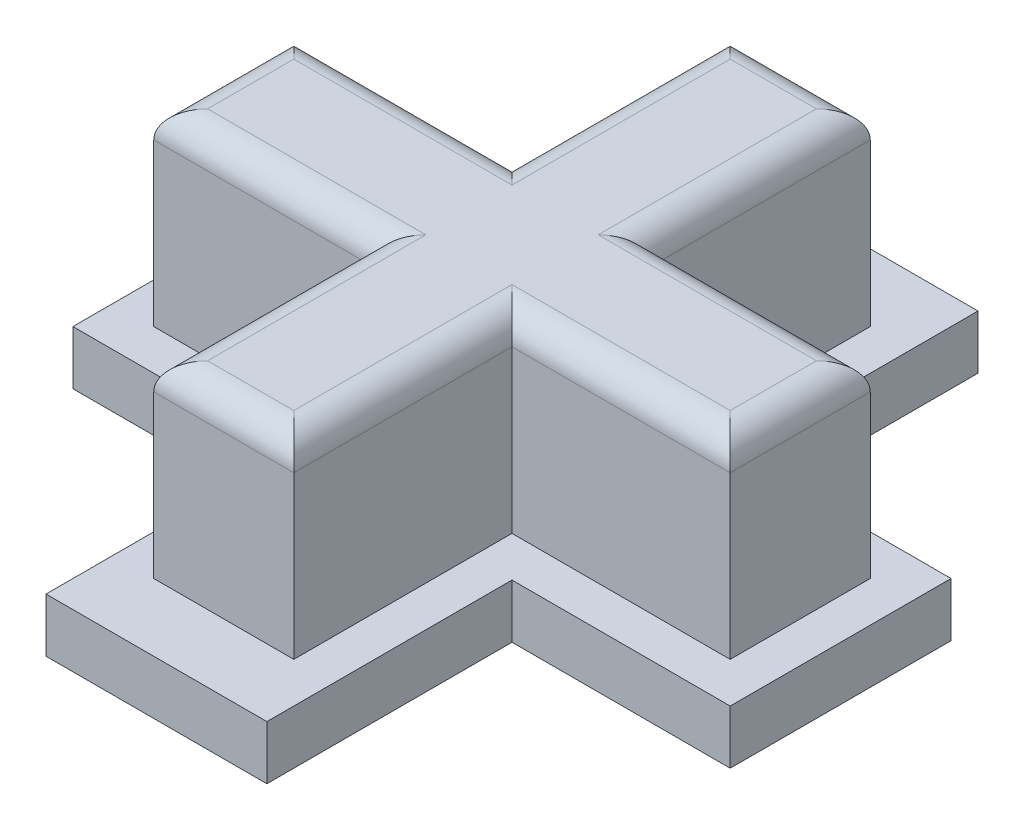
from build123d import *

# Parameters (mm, degrees)
BOSS_EXTRUDE1_DEPTH = 2
BOSS_EXTRUDE3_DEPTH = 7
FILLET5_R           = 1


with BuildPart() as part:
    # Sketch1 → Boss-Extrude1 (new body)
    with BuildSketch(Plane(origin=(0, 0, 0), x_dir=(1, 0, 0), z_dir=(0, 1, 0))):
        Polygon((4.1, -4.1), (4.1, -13.2), (-4.1, -13.2), (-4.1, -4.1), (-12.2, -4.1), (-12.2, 4.1), (-4.1, 4.1), (-4.1, 13.2), (4.1, 13.2), (4.1, 4.1), (12.2, 4.1), (12.2, -4.1), align=None)
    extrude(amount=BOSS_EXTRUDE1_DEPTH)

    # Sketch4 → Boss-Extrude3 (add)
    with BuildSketch(Plane(origin=(0, 2, 0), x_dir=(1, 0, 0), z_dir=(0, 1, 0))):
        Polygon((10.7, -2.6), (5.5, -2.6), (2.6, -2.6), (2.6, -10.7), (-2.6, -10.7), (-2.6, -2.6), (-10.7, -2.6), (-10.7, 2.6), (-5.5, 2.6), (-2.6, 2.6), (-2.6, 10.7), (2.6, 10.7), (2.6, 2.6), (5.5, 2.6), (10.7, 2.6), align=None)
    extrude(amount=BOSS_EXTRUDE3_DEPTH)

    # Fillet5
    fillet5_edges = [part.edges().sort_by_distance(p)[0] for p in [
        (6.65, 9, -2.6),
        (2.6, 9, -6.65),
        (0, 9, -10.7),
        (-2.6, 9, -6.65),
        (-6.65, 9, -2.6),
        (-10.7, 9, 0),
        (-6.65, 9, 2.6),
        (-2.6, 9, 6.65),
        (0, 9, 10.7),
        (2.6, 9, 6.65),
        (6.65, 9, 2.6),
        (10.7, 9, 0),
    ]]
    fillet(fillet5_edges, radius=FILLET5_R)


solid = part.part
